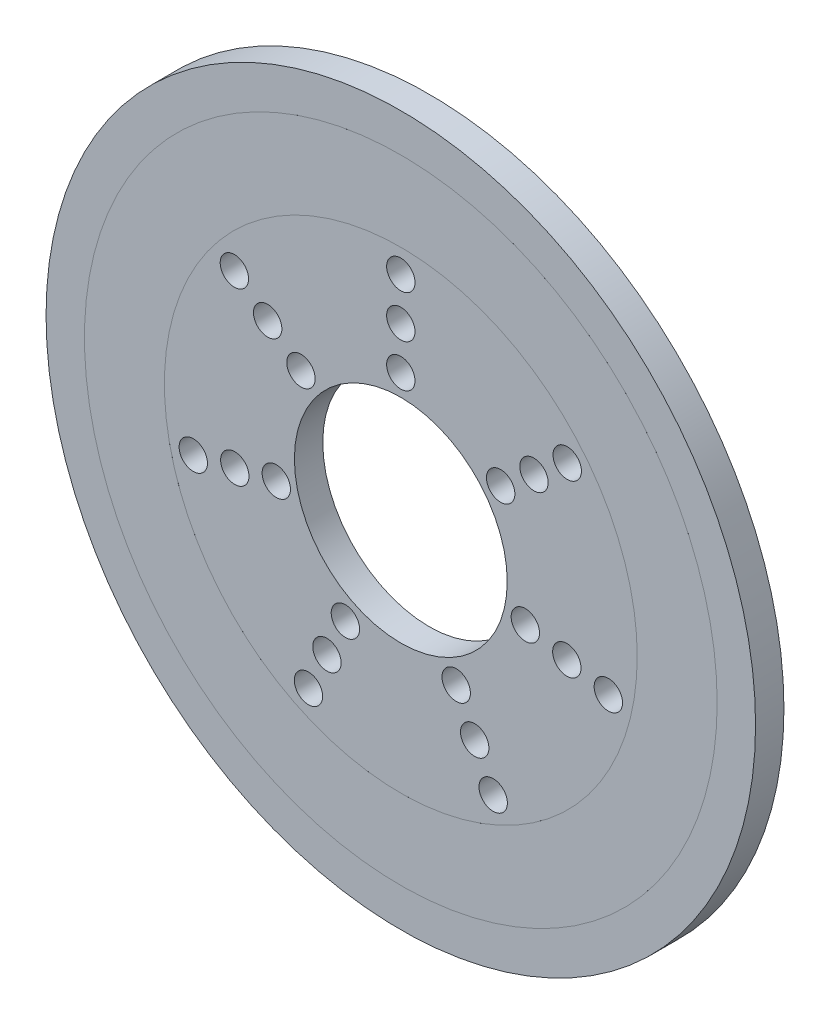
from build123d import *

# Parameters (mm, degrees)
SKETCH1_R           = 125
SKETCH1_R_2         = 37.5
SKETCH1_R_3         = 5
BOSS_EXTRUDE2_DEPTH = 10
SKETCH2_R           = 111.468965798
SKETCH2_R_2         = 83.303584862
BOSS_EXTRUDE3_DEPTH = 10.001
BOSS_EXTRUDE4_START = 0.001
SKETCH2_2_R         = 111.468965798
SKETCH2_2_R_2       = 83.303584862
BOSS_EXTRUDE4_DEPTH = 0.001


with BuildPart() as part:
    # Sketch1 → Boss-Extrude2 (new body)
    with BuildSketch(Plane.XY):
        Circle(SKETCH1_R)
        Circle(SKETCH1_R_2, mode=Mode.SUBTRACT)
        with Locations((0, 45)):
            Circle(SKETCH1_R_3, mode=Mode.SUBTRACT)
        with Locations((0, 60)):
            Circle(SKETCH1_R_3, mode=Mode.SUBTRACT)
        with Locations((0, 75)):
            Circle(SKETCH1_R_3, mode=Mode.SUBTRACT)
        with Locations((0, 90)):
            Circle(SKETCH1_R_3, mode=Mode.SUBTRACT)
        with Locations((0, 105)):
            Circle(SKETCH1_R_3, mode=Mode.SUBTRACT)
        with Locations((82.092305659, 65.466429195)):
            Circle(SKETCH1_R_3, mode=Mode.SUBTRACT)
        with Locations((70.364833422, 56.114082167)):
            Circle(SKETCH1_R_3, mode=Mode.SUBTRACT)
        with Locations((58.637361185, 46.761735139)):
            Circle(SKETCH1_R_3, mode=Mode.SUBTRACT)
        with Locations((46.909888948, 37.409388112)):
            Circle(SKETCH1_R_3, mode=Mode.SUBTRACT)
        with Locations((35.182416711, 28.057041084)):
            Circle(SKETCH1_R_3, mode=Mode.SUBTRACT)
        with Locations((102.367430779, -23.364698065)):
            Circle(SKETCH1_R_3, mode=Mode.SUBTRACT)
        with Locations((87.743512096, -20.026884056)):
            Circle(SKETCH1_R_3, mode=Mode.SUBTRACT)
        with Locations((73.119593414, -16.689070047)):
            Circle(SKETCH1_R_3, mode=Mode.SUBTRACT)
        with Locations((58.495674731, -13.351256037)):
            Circle(SKETCH1_R_3, mode=Mode.SUBTRACT)
        with Locations((43.871756048, -10.013442028)):
            Circle(SKETCH1_R_3, mode=Mode.SUBTRACT)
        with Locations((45.557792607, -94.60173113)):
            Circle(SKETCH1_R_3, mode=Mode.SUBTRACT)
        with Locations((39.049536521, -81.087198111)):
            Circle(SKETCH1_R_3, mode=Mode.SUBTRACT)
        with Locations((32.541280434, -67.572665093)):
            Circle(SKETCH1_R_3, mode=Mode.SUBTRACT)
        with Locations((26.033024347, -54.058132074)):
            Circle(SKETCH1_R_3, mode=Mode.SUBTRACT)
        with Locations((19.52476826, -40.543599056)):
            Circle(SKETCH1_R_3, mode=Mode.SUBTRACT)
        with Locations((-45.557792607, -94.60173113)):
            Circle(SKETCH1_R_3, mode=Mode.SUBTRACT)
        with Locations((-39.049536521, -81.087198111)):
            Circle(SKETCH1_R_3, mode=Mode.SUBTRACT)
        with Locations((-32.541280434, -67.572665093)):
            Circle(SKETCH1_R_3, mode=Mode.SUBTRACT)
        with Locations((-26.033024347, -54.058132074)):
            Circle(SKETCH1_R_3, mode=Mode.SUBTRACT)
        with Locations((-19.52476826, -40.543599056)):
            Circle(SKETCH1_R_3, mode=Mode.SUBTRACT)
        with Locations((-102.367430779, -23.364698065)):
            Circle(SKETCH1_R_3, mode=Mode.SUBTRACT)
        with Locations((-87.743512096, -20.026884056)):
            Circle(SKETCH1_R_3, mode=Mode.SUBTRACT)
        with Locations((-73.119593414, -16.689070047)):
            Circle(SKETCH1_R_3, mode=Mode.SUBTRACT)
        with Locations((-58.495674731, -13.351256037)):
            Circle(SKETCH1_R_3, mode=Mode.SUBTRACT)
        with Locations((-43.871756048, -10.013442028)):
            Circle(SKETCH1_R_3, mode=Mode.SUBTRACT)
        with Locations((-82.092305659, 65.466429195)):
            Circle(SKETCH1_R_3, mode=Mode.SUBTRACT)
        with Locations((-70.364833422, 56.114082167)):
            Circle(SKETCH1_R_3, mode=Mode.SUBTRACT)
        with Locations((-58.637361185, 46.761735139)):
            Circle(SKETCH1_R_3, mode=Mode.SUBTRACT)
        with Locations((-46.909888948, 37.409388112)):
            Circle(SKETCH1_R_3, mode=Mode.SUBTRACT)
        with Locations((-35.182416711, 28.057041084)):
            Circle(SKETCH1_R_3, mode=Mode.SUBTRACT)
    extrude(amount=BOSS_EXTRUDE2_DEPTH)

    # Sketch2 → Boss-Extrude3 (add)
    with BuildSketch(Plane.XY.offset(10)):
        Circle(SKETCH2_R)
        Circle(SKETCH2_R_2, mode=Mode.SUBTRACT)
    extrude(amount=-BOSS_EXTRUDE3_DEPTH)

    # Sketch2_2 → Boss-Extrude4 (add)
    with BuildSketch(Plane.XY.offset(10).offset(BOSS_EXTRUDE4_START)):
        Circle(SKETCH2_2_R)
        Circle(SKETCH2_2_R_2, mode=Mode.SUBTRACT)
    extrude(amount=-BOSS_EXTRUDE4_DEPTH)


solid = part.part
